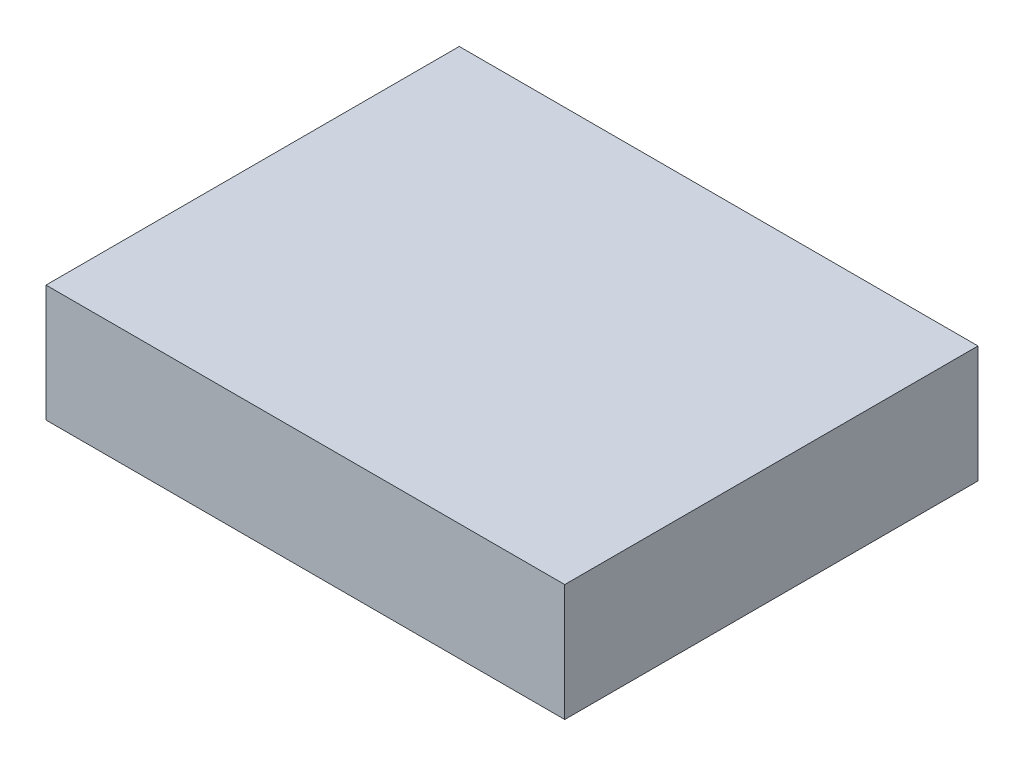
from build123d import *

# Parameters (mm, degrees)
SKETCH1_W           = 95.4
SKETCH1_H           = 76
BOSS_EXTRUDE1_DEPTH = 21.5


with BuildPart() as part:
    # Sketch1 → Boss-Extrude1 (new body)
    with BuildSketch(Plane(origin=(0, 0, 0), x_dir=(1, 0, 0), z_dir=(0, 1, 0))):
        Rectangle(SKETCH1_W, SKETCH1_H)
    extrude(amount=BOSS_EXTRUDE1_DEPTH)


solid = part.part
